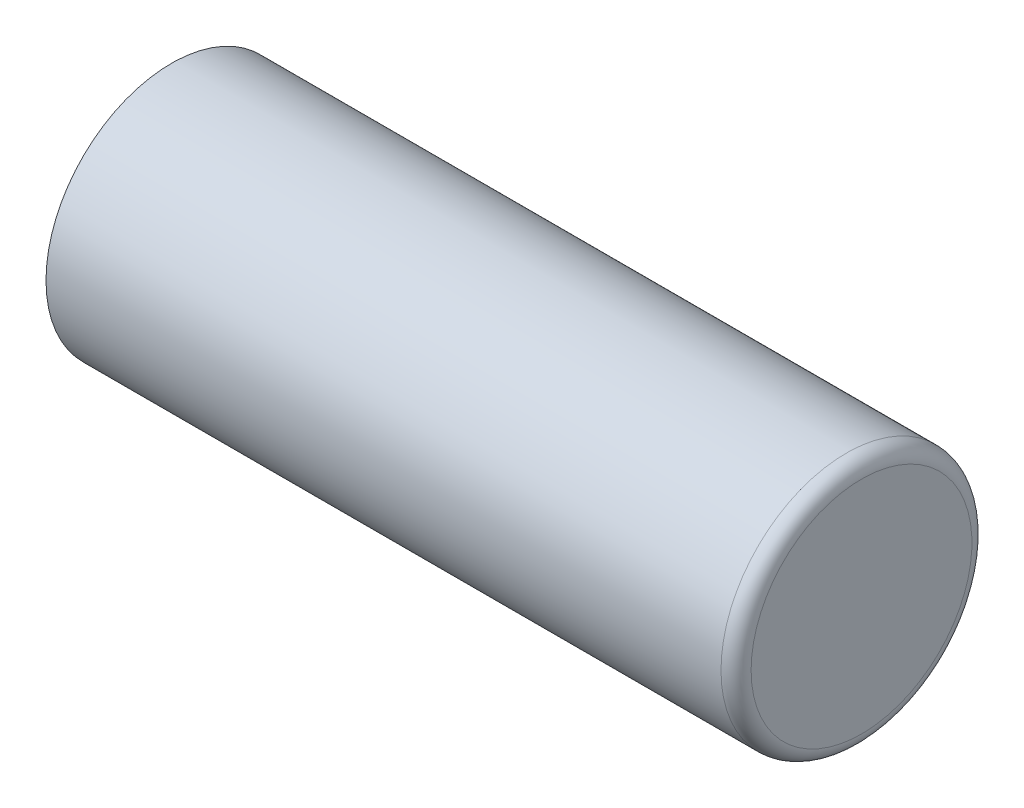
from build123d import *


with BuildPart() as part:
    # Sketch1 → Revolve1 (revolve)
    with BuildSketch(Plane(origin=(0, 0, 0), x_dir=(1, 0, 0), z_dir=(0, 1, 0))):
        with BuildLine():
            Line((0, 0), (3.175, 0))
            Line((3.175, 0), (3.175, 11.176))
            ThreePointArc((3.175, 11.176), (2.728630735, 12.253630735), (1.651, 12.7))
            Line((1.651, 12.7), (-66.675, 12.7))
            Line((-66.675, 12.7), (-66.675, 11.1125))
            Line((-66.675, 11.1125), (-65.0748, 11.1125))
            Line((-65.0748, 11.1125), (-65.0748, 9.525))
            Line((-65.0748, 9.525), (-1.524, 9.525))
            ThreePointArc((-1.524, 9.525), (-0.446369265, 9.078630735), (0, 8.001))
            Line((0, 8.001), (0, 0))
        make_face()
    revolve(axis=Axis((0, 0, 0), (1, 0, 0)))


solid = part.part
